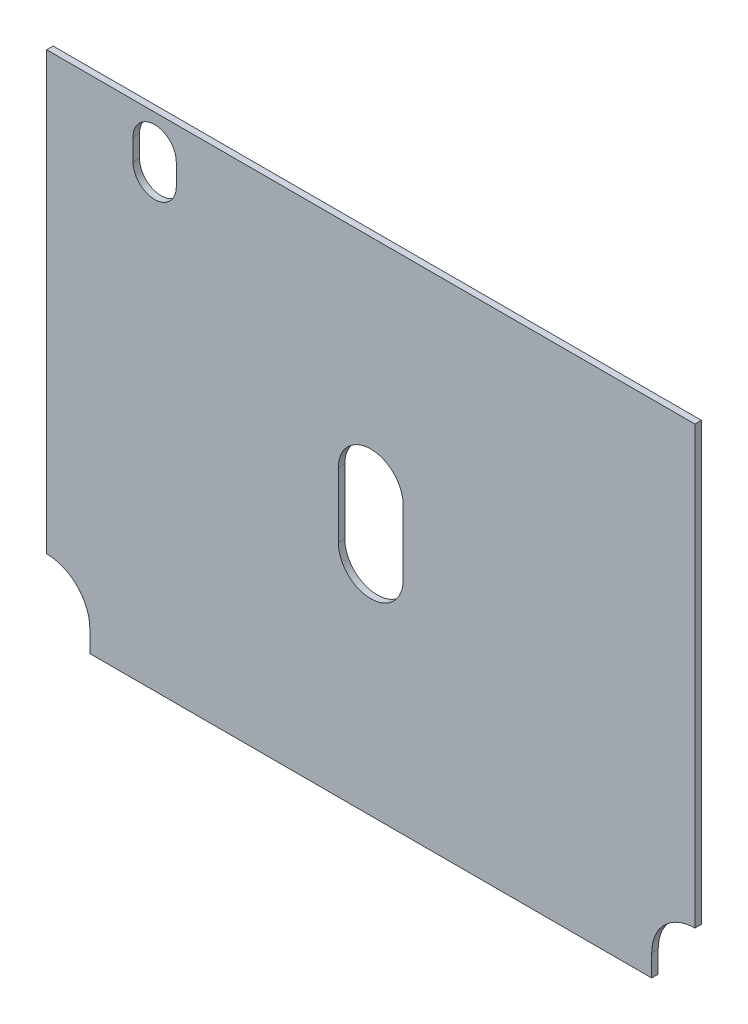
from build123d import *

# Parameters (mm, degrees)
EXTRUSION1_DEPTH = 3


with BuildPart() as part:
    # Esquisse1 → Extrusion1 (new body)
    with BuildSketch(Plane.XY):
        with BuildLine():
            Line((150, 232), (-150, 232))
            Line((-150, 232), (-150, 30))
            ThreePointArc((-150, 30), (-135.857864376, 24.142135624), (-130, 10))
            Line((-130, 10), (-130, 0))
            Line((-130, 0), (130, 0))
            Line((130, 0), (130, 10))
            ThreePointArc((130, 10), (135.857864376, 24.142135624), (150, 30))
            Line((150, 30), (150, 232))
        make_face()
        with BuildLine():
            Line((-15, 102), (-15, 132))
            ThreePointArc((-15, 132), (0, 147), (15, 132))
            Line((15, 132), (15, 102))
            ThreePointArc((15, 102), (0, 87), (-15, 102))
        make_face(mode=Mode.SUBTRACT)
        with BuildLine():
            Line((-110, 207), (-110, 217))
            ThreePointArc((-110, 217), (-100, 227), (-90, 217))
            Line((-90, 217), (-90, 207))
            ThreePointArc((-90, 207), (-100, 197), (-110, 207))
        make_face(mode=Mode.SUBTRACT)
    extrude(amount=EXTRUSION1_DEPTH)


solid = part.part
